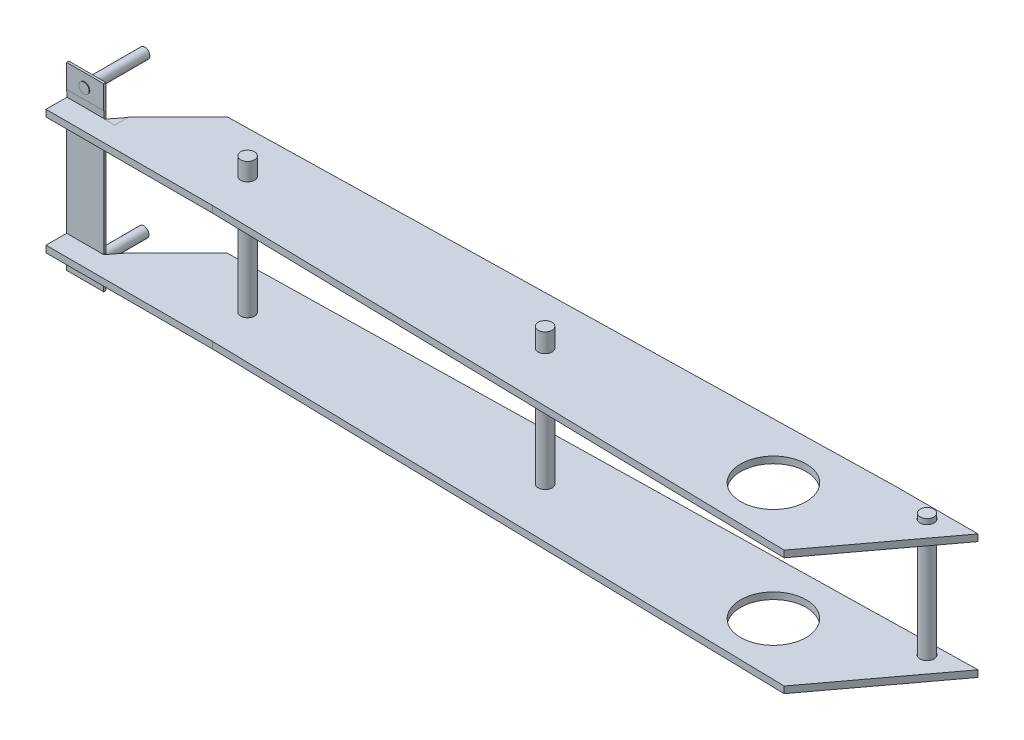
from build123d import *

# Parameters (mm, degrees)
SALIENTE_EXTRUIR2_DEPTH       = 4.572
CROQUIS4_R                    = 4.7625
CORTAR_EXTRUIR2_DEPTH         = 152.654
CORTAR_EXTRUIR2_DEPTH_BACK    = 98.552
CROQUIS5_R                    = 7.9375
CORTAR_EXTRUIR5_DEPTH         = 47.498
CORTAR_EXTRUIR5_DEPTH_BACK    = 59.182
CROQUIS6_R                    = 4.7625
SALIENTE_EXTRUIR4_DEPTH       = 17.526
SALIENTE_EXTRUIR4_DEPTH_BACK  = 94.488
CROQUIS7_R                    = 4.7625
SALIENTE_EXTRUIR5_DEPTH       = 16.002
SALIENTE_EXTRUIR5_DEPTH_BACK  = 97.536
CROQUIS10_R                   = 7.9375
SALIENTE_EXTRUIR6_DEPTH       = 4.572
CROQUIS11_R                   = 22.479
CORTAR_EXTRUIR6_DEPTH         = 97.282
CORTAR_EXTRUIR6_DEPTH_BACK    = 123.444
CROQUIS12_R                   = 4.826
CORTAR_EXTRUIR7_DEPTH         = 113.792
CORTAR_EXTRUIR7_DEPTH_BACK    = 187.96
CROQUIS13_R                   = 4.671315892
SALIENTE_EXTRUIR8_DEPTH       = 3.556
SALIENTE_EXTRUIR8_DEPTH_BACK  = 87.884
CORTAR_EXTRUIR8_DEPTH         = 84.074
CORTAR_EXTRUIR8_DEPTH_BACK    = 142.748
CROQUIS15_W                   = 114.3
CROQUIS15_H                   = 14.18647629
SALIENTE_EXTRUIR13_DEPTH      = 9.398
SALIENTE_EXTRUIR13_DEPTH_BACK = 86.106
CROQUIS17_W                   = 25.456436791
CROQUIS17_H                   = 1.513590227
SALIENTE_EXTRUIR14_DEPTH      = 25.4
SALIENTE_EXTRUIR14_DEPTH_BACK = 98.298
CROQUIS18_W                   = 13.736168234
CROQUIS18_H                   = 76.2
CORTAR_EXTRUIR9_DEPTH         = 127.508
CROQUIS19_W                   = 14.167732796
CROQUIS19_H                   = 72.287064097
CORTAR_EXTRUIR12_DEPTH        = 127.508
CROQUIS20_W                   = 71.243454513
CROQUIS20_H                   = 66.240283729
CORTAR_EXTRUIR13_DEPTH        = 289.306
CORTAR_EXTRUIR13_DEPTH_BACK   = 150.368
CORTAR_EXTRUIR14_DEPTH        = 662.432
CORTAR_EXTRUIR14_DEPTH_BACK   = 12.7
CORTAR_EXTRUIR15_DEPTH        = 397.51
CROQUIS23_R                   = 4.7625
SALIENTE_EXTRUIR15_DEPTH      = 16.764
SALIENTE_EXTRUIR15_DEPTH_BACK = 95.504
CORTAR_EXTRUIR17_DEPTH        = 83.566
CORTAR_EXTRUIR17_DEPTH_BACK   = 37.846
CROQUIS25_W                   = 14.18647629
CROQUIS25_H                   = 5.334
CORTAR_EXTRUIR18_DEPTH        = 88.138
CORTAR_EXTRUIR18_DEPTH_BACK   = 41.402
CROQUIS26_W                   = 14.019306629
CROQUIS26_H                   = 1.708052777
CORTAR_EXTRUIR19_DEPTH        = 41.402
CORTAR_EXTRUIR19_DEPTH_BACK   = 67.31
CROQUIS27_W                   = 14.167732796
CROQUIS27_H                   = 2.204883126
CORTAR_EXTRUIR20_DEPTH        = 48.26
CORTAR_EXTRUIR20_DEPTH_BACK   = 71.628
CROQUIS28_W                   = 7.614539368
CROQUIS28_H                   = 74.491947223
CORTAR_EXTRUIR21_DEPTH        = 254
CROQUIS29_W                   = 7.498830198
CROQUIS29_H                   = 1.708052777
CORTAR_EXTRUIR22_DEPTH        = 340.106
SALIENTE_EXTRUIR19_DEPTH      = 4.318
SALIENTE_EXTRUIR19_DEPTH_BACK = 80.264
CROQUIS32_W                   = 7.476401903
CROQUIS32_H                   = 76.2
CORTAR_EXTRUIR24_DEPTH        = 209.042
CROQUIS33_R                   = 3.528685289
SALIENTE_EXTRUIR20_DEPTH      = 111.76
CROQUIS34_W                   = 7.057370577
CROQUIS34_H                   = 70.026056614
CORTAR_EXTRUIR25_DEPTH        = 200.406
CROQUIS35_R                   = 3.556
SALIENTE_EXTRUIR21_DEPTH      = 110.998
SALIENTE_EXTRUIR21_DEPTH_BACK = 5.08
CROQUIS36_W                   = 75.760333747
CROQUIS36_H                   = 7.112
CORTAR_EXTRUIR26_DEPTH        = 55.626
CORTAR_EXTRUIR26_DEPTH_BACK   = 67.818


with BuildPart() as part:
    # Croquis1 → Saliente-Extruir2 (new body)
    with BuildSketch(Plane(origin=(0, 0, 0), x_dir=(1, 0, 0), z_dir=(0, 1, 0))):
        Polygon((-101.794045487, -70.698494166), (-101.794045487, -121.498494166), (482.405954513, -134.198494166), (539.316670094, -57.998494166), (482.405954513, -57.998494166), align=None)
    extrude(amount=SALIENTE_EXTRUIR2_DEPTH)

    # Croquis4 → Cortar-Extruir2 (cut, two sides)
    with BuildSketch(Plane(origin=(0, 0, 0), x_dir=(1, 0, 0), z_dir=(0, 1, 0))) as cortar_extruir2_sk:
        with Locations((76.005954513, -96.098494166)):
            Circle(CROQUIS4_R)
        with Locations((280.239325042, -96.098494166)):
            Circle(CROQUIS4_R)
    extrude(amount=CORTAR_EXTRUIR2_DEPTH, mode=Mode.SUBTRACT)
    extrude(cortar_extruir2_sk.sketch, amount=-CORTAR_EXTRUIR2_DEPTH_BACK, mode=Mode.SUBTRACT)

    # Croquis5 → Cortar-Extruir5 (cut, two sides)
    with BuildSketch(Plane(origin=(0, 0, 0), x_dir=(1, 0, 0), z_dir=(0, 1, 0))) as cortar_extruir5_sk:
        with Locations((438.694154646, -97.820081973)):
            Circle(CROQUIS5_R)
    extrude(amount=CORTAR_EXTRUIR5_DEPTH, mode=Mode.SUBTRACT)
    extrude(cortar_extruir5_sk.sketch, amount=-CORTAR_EXTRUIR5_DEPTH_BACK, mode=Mode.SUBTRACT)

    # Croquis6 → Saliente-Extruir4 (add, two sides)
    with BuildSketch(Plane(origin=(0, 0, 0), x_dir=(1, 0, 0), z_dir=(0, 1, 0))) as saliente_extruir4_sk:
        with Locations((280.239325042, -96.098494166)):
            Circle(CROQUIS6_R)
    extrude(amount=SALIENTE_EXTRUIR4_DEPTH)
    extrude(saliente_extruir4_sk.sketch, amount=-SALIENTE_EXTRUIR4_DEPTH_BACK)

    # Croquis7 → Saliente-Extruir5 (add, two sides)
    with BuildSketch(Plane(origin=(0, 0, 0), x_dir=(1, 0, 0), z_dir=(0, 1, 0))) as saliente_extruir5_sk:
        with Locations((76.005954513, -96.098494166)):
            Circle(CROQUIS7_R)
    extrude(amount=SALIENTE_EXTRUIR5_DEPTH)
    extrude(saliente_extruir5_sk.sketch, amount=-SALIENTE_EXTRUIR5_DEPTH_BACK)

    # Croquis10 → Saliente-Extruir6 (add)
    with BuildSketch(Plane(origin=(0, -76.2, 0), x_dir=(-1, 0, 0), z_dir=(0, -1, 0))):
        Polygon((-539.316670094, -57.998494166), (101.794045487, -70.698494166), (101.794045487, -121.498494166), (-482.405954513, -134.198494166), align=None)
        with Locations((-438.694154646, -97.820081973)):
            Circle(CROQUIS10_R, mode=Mode.SUBTRACT)
    extrude(amount=SALIENTE_EXTRUIR6_DEPTH)

    # Croquis11 → Cortar-Extruir6 (cut, two sides)
    with BuildSketch(Plane(origin=(0, 0, 0), x_dir=(1, 0, 0), z_dir=(0, 1, 0))) as cortar_extruir6_sk:
        with Locations((438.694154646, -97.820081973)):
            Circle(CROQUIS11_R)
    extrude(amount=CORTAR_EXTRUIR6_DEPTH, mode=Mode.SUBTRACT)
    extrude(cortar_extruir6_sk.sketch, amount=-CORTAR_EXTRUIR6_DEPTH_BACK, mode=Mode.SUBTRACT)

    # Croquis12 → Cortar-Extruir7 (cut, two sides)
    with BuildSketch(Plane(origin=(0, 0, 0), x_dir=(1, 0, 0), z_dir=(0, 1, 0))) as cortar_extruir7_sk:
        with Locations((512.976925935, -66.629402009)):
            Circle(CROQUIS12_R)
    extrude(amount=CORTAR_EXTRUIR7_DEPTH, mode=Mode.SUBTRACT)
    extrude(cortar_extruir7_sk.sketch, amount=-CORTAR_EXTRUIR7_DEPTH_BACK, mode=Mode.SUBTRACT)

    # Croquis14 → Cortar-Extruir8 (cut, two sides)
    with BuildSketch(Plane(origin=(0, 0, 0), x_dir=(1, 0, 0), z_dir=(0, 1, 0))) as cortar_extruir8_sk:
        Polygon((33.849548038, -67.749720393), (0, -101.599268431), (0, -123.711408198), (-101.794045487, -121.498494166), (-101.794045487, -70.698494166), align=None)
    extrude(amount=CORTAR_EXTRUIR8_DEPTH, mode=Mode.SUBTRACT)
    extrude(cortar_extruir8_sk.sketch, amount=-CORTAR_EXTRUIR8_DEPTH_BACK, mode=Mode.SUBTRACT)

    # Croquis15 → Saliente-Extruir13 (add, two sides)
    with BuildSketch(Plane(origin=(0, 0, 0), x_dir=(1, 0, 0), z_dir=(0, 1, 0))) as saliente_extruir13_sk:
        with Locations((24.153600026, -118.385639619)):
            Rectangle(CROQUIS15_W, CROQUIS15_H)
    extrude(amount=SALIENTE_EXTRUIR13_DEPTH)
    extrude(saliente_extruir13_sk.sketch, amount=-SALIENTE_EXTRUIR13_DEPTH_BACK)

    # Croquis17 → Saliente-Extruir14 (add, two sides)
    with BuildSketch(Plane(origin=(0, 0, 0), x_dir=(1, 0, 0), z_dir=(0, 1, 0))) as saliente_extruir14_sk:
        with Locations((-20.268181578, -110.53560636)):
            Rectangle(CROQUIS17_W, CROQUIS17_H)
    extrude(amount=SALIENTE_EXTRUIR14_DEPTH)
    extrude(saliente_extruir14_sk.sketch, amount=-SALIENTE_EXTRUIR14_DEPTH_BACK)

    # Croquis18 → Cortar-Extruir9 (cut)
    with BuildSketch(Plane(origin=(0, 0, 0), x_dir=(0, 0, -1), z_dir=(1, 0, 0))):
        with Locations((-118.610793647, -38.1)):
            Rectangle(CROQUIS18_W, CROQUIS18_H)
    extrude(amount=CORTAR_EXTRUIR9_DEPTH, mode=Mode.SUBTRACT)

    # Croquis19 → Cortar-Extruir12 (cut)
    with BuildSketch(Plane(origin=(0, 0, 0), x_dir=(0, 0, -1), z_dir=(1, 0, 0))):
        with Locations((-118.395011366, -37.851584826)):
            Rectangle(CROQUIS19_W, CROQUIS19_H)
    extrude(amount=-CORTAR_EXTRUIR12_DEPTH, mode=Mode.SUBTRACT)

    # Croquis20 → Cortar-Extruir13 (cut, two sides)
    with BuildSketch(Plane.XY.offset(111.74270953)) as cortar_extruir13_sk:
        with Locations((35.621727257, -38.064616677)):
            Rectangle(CROQUIS20_W, CROQUIS20_H)
    extrude(amount=CORTAR_EXTRUIR13_DEPTH, mode=Mode.SUBTRACT)
    extrude(cortar_extruir13_sk.sketch, amount=-CORTAR_EXTRUIR13_DEPTH_BACK, mode=Mode.SUBTRACT)

    # Croquis21 → Cortar-Extruir14 (cut, two sides)
    with BuildSketch(Plane.XY) as cortar_extruir14_sk:
        Polygon((71.243454513, -4.944474812), (71.243454513, -71.184758541), (81.303600026, -76.2), (81.303600026, 0), (0, 0), (0, -4.944474812), align=None)
    extrude(amount=CORTAR_EXTRUIR14_DEPTH, mode=Mode.SUBTRACT)
    extrude(cortar_extruir14_sk.sketch, amount=-CORTAR_EXTRUIR14_DEPTH_BACK, mode=Mode.SUBTRACT)

    # Croquis22 → Cortar-Extruir15 (cut)
    with BuildSketch(Plane.XY):
        Polygon((71.243454513, -71.184758541), (0, -71.184758541), (0, -76.2), (81.544591258, -76.2), align=None)
    extrude(amount=CORTAR_EXTRUIR15_DEPTH, mode=Mode.SUBTRACT)

    # Croquis23 → Saliente-Extruir15 (add, two sides)
    with BuildSketch(Plane(origin=(0, 0, 0), x_dir=(1, 0, 0), z_dir=(0, 1, 0))) as saliente_extruir15_sk:
        with Locations((76.005954513, -96.098494166)):
            Circle(CROQUIS23_R)
    extrude(amount=SALIENTE_EXTRUIR15_DEPTH)
    extrude(saliente_extruir15_sk.sketch, amount=-SALIENTE_EXTRUIR15_DEPTH_BACK)

    # Croquis24 → Cortar-Extruir17 (cut, two sides)
    with BuildSketch(Plane(origin=(0, 0, 0), x_dir=(0, 0, -1), z_dir=(1, 0, 0))) as cortar_extruir17_sk:
        Polygon((-125.478877764, 4.572), (-111.095362687, 4.572), (-111.292401474, 9.398), (-125.478877764, 9.398), align=None)
    extrude(amount=CORTAR_EXTRUIR17_DEPTH, mode=Mode.SUBTRACT)
    extrude(cortar_extruir17_sk.sketch, amount=-CORTAR_EXTRUIR17_DEPTH_BACK, mode=Mode.SUBTRACT)

    # Croquis25 → Cortar-Extruir18 (cut, two sides)
    with BuildSketch(Plane(origin=(0, 0, 0), x_dir=(0, 0, -1), z_dir=(1, 0, 0))) as cortar_extruir18_sk:
        with Locations((-118.385639619, -83.439)):
            Rectangle(CROQUIS25_W, CROQUIS25_H)
    extrude(amount=CORTAR_EXTRUIR18_DEPTH, mode=Mode.SUBTRACT)
    extrude(cortar_extruir18_sk.sketch, amount=-CORTAR_EXTRUIR18_DEPTH_BACK, mode=Mode.SUBTRACT)

    # Croquis26 → Cortar-Extruir19 (cut, two sides)
    with BuildSketch(Plane(origin=(0, 0, 0), x_dir=(0, 0, -1), z_dir=(1, 0, 0))) as cortar_extruir19_sk:
        with Locations((-118.46922445, -0.854026389)):
            Rectangle(CROQUIS26_W, CROQUIS26_H)
    extrude(amount=CORTAR_EXTRUIR19_DEPTH, mode=Mode.SUBTRACT)
    extrude(cortar_extruir19_sk.sketch, amount=-CORTAR_EXTRUIR19_DEPTH_BACK, mode=Mode.SUBTRACT)

    # Croquis27 → Cortar-Extruir20 (cut, two sides)
    with BuildSketch(Plane(origin=(0, 0, 0), x_dir=(0, 0, -1), z_dir=(1, 0, 0))) as cortar_extruir20_sk:
        with Locations((-118.395011366, -75.097558437)):
            Rectangle(CROQUIS27_W, CROQUIS27_H)
    extrude(amount=CORTAR_EXTRUIR20_DEPTH, mode=Mode.SUBTRACT)
    extrude(cortar_extruir20_sk.sketch, amount=-CORTAR_EXTRUIR20_DEPTH_BACK, mode=Mode.SUBTRACT)

    # Croquis28 → Cortar-Extruir21 (cut)
    with BuildSketch(Plane.XY):
        with Locations((-3.807269684, -38.954026389)):
            Rectangle(CROQUIS28_W, CROQUIS28_H)
    extrude(amount=CORTAR_EXTRUIR21_DEPTH, mode=Mode.SUBTRACT)

    # Croquis29 → Cortar-Extruir22 (cut)
    with BuildSketch(Plane.XY):
        with Locations((-3.749415099, -0.854026389)):
            Rectangle(CROQUIS29_W, CROQUIS29_H)
    extrude(amount=CORTAR_EXTRUIR22_DEPTH, mode=Mode.SUBTRACT)

    # Croquis30 → Saliente-Extruir19 (add, two sides)
    with BuildSketch(Plane(origin=(0, 0, 0), x_dir=(1, 0, 0), z_dir=(0, 1, 0))) as saliente_extruir19_sk:
        Polygon((-7.539963183, -111.292401474), (0, -101.599268431), (0, -111.292401474), align=None)
    extrude(amount=SALIENTE_EXTRUIR19_DEPTH)
    extrude(saliente_extruir19_sk.sketch, amount=-SALIENTE_EXTRUIR19_DEPTH_BACK)

    # Croquis32 → Cortar-Extruir24 (cut)
    with BuildSketch(Plane.XY):
        with Locations((-3.738200952, -38.1)):
            Rectangle(CROQUIS32_W, CROQUIS32_H)
    extrude(amount=CORTAR_EXTRUIR24_DEPTH, mode=Mode.SUBTRACT)

    # Croquis33 → Saliente-Extruir20 (add)
    with BuildSketch(Plane.XY):
        with Locations((-20.646499343, 16.53272161)):
            Circle(CROQUIS33_R)
    extrude(amount=SALIENTE_EXTRUIR20_DEPTH)

    # Croquis34 → Cortar-Extruir25 (cut)
    with BuildSketch(Plane(origin=(0, 0, 0), x_dir=(1, 0, 0), z_dir=(0, 1, 0))):
        with Locations((-20.646499343, -35.013028307)):
            Rectangle(CROQUIS34_W, CROQUIS34_H)
    extrude(amount=CORTAR_EXTRUIR25_DEPTH, mode=Mode.SUBTRACT)

    # Croquis35 → Saliente-Extruir21 (add, two sides)
    with BuildSketch(Plane.XY) as saliente_extruir21_sk:
        with Locations((-20.646499343, -89.439131113)):
            Circle(CROQUIS35_R)
    extrude(amount=SALIENTE_EXTRUIR21_DEPTH)
    extrude(saliente_extruir21_sk.sketch, amount=-SALIENTE_EXTRUIR21_DEPTH_BACK)

    # Croquis36 → Cortar-Extruir26 (cut, two sides)
    with BuildSketch(Plane.ZY.offset(32.996399974)) as cortar_extruir26_sk:
        with Locations((32.800166874, -89.439131113)):
            Rectangle(CROQUIS36_W, CROQUIS36_H)
    extrude(amount=CORTAR_EXTRUIR26_DEPTH, mode=Mode.SUBTRACT)
    extrude(cortar_extruir26_sk.sketch, amount=-CORTAR_EXTRUIR26_DEPTH_BACK, mode=Mode.SUBTRACT)


with BuildPart() as body_2:
    # Croquis13 → Saliente-Extruir8 (new body, two sides)
    with BuildSketch(Plane(origin=(0, 4.572, 0), x_dir=(1, 0, 0), z_dir=(0, 1, 0))) as saliente_extruir8_sk:
        with Locations((512.976925935, -66.629402009)):
            Circle(CROQUIS13_R)
    extrude(amount=SALIENTE_EXTRUIR8_DEPTH)
    extrude(saliente_extruir8_sk.sketch, amount=-SALIENTE_EXTRUIR8_DEPTH_BACK)


solid = Compound([part.part, body_2.part])
